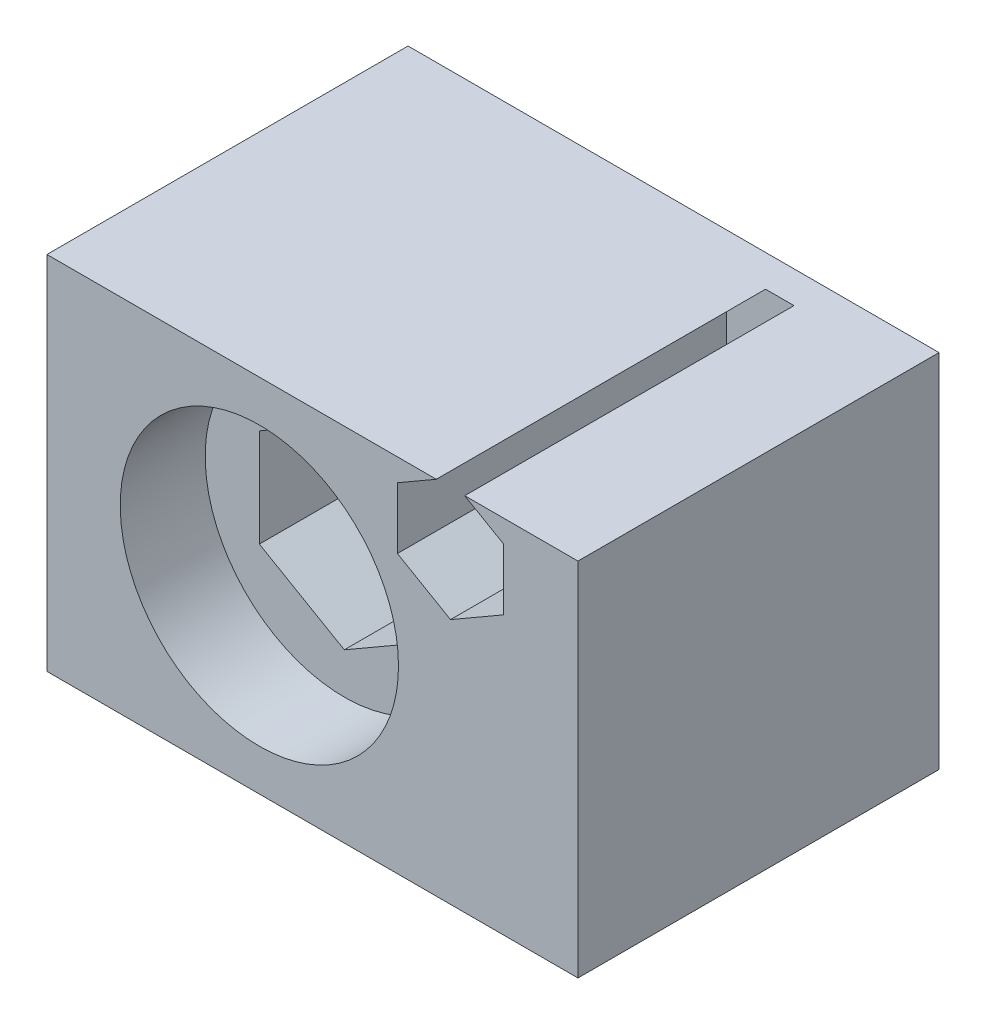
from build123d import *

# Parameters (mm, degrees)
SKETCH_1_W          = 18
SKETCH_1_H          = 18
EXTRUDE_1_DEPTH     = 25
SKETCH_2_R          = 6.55
CUT_EXTRUDE_1_DEPTH = 4.5
CUT_EXTRUDE_2_DEPTH = 11.7
CUT_EXTRUDE_3_DEPTH = 16
SKETCH_6_W          = 18
SKETCH_6_H          = 18
SKETCH_6_W_2        = 17
SKETCH_6_H_2        = 17
CUT_EXTRUDE_5_DEPTH = 26


with BuildPart() as part:
    # 草图1 → 凸台-拉伸1 (new body)
    with BuildSketch(Plane(origin=(0, 0, 0), x_dir=(0, 0, -1), z_dir=(1, 0, 0))):
        with Locations((9, 9)):
            Rectangle(SKETCH_1_W, SKETCH_1_H)
    extrude(amount=EXTRUDE_1_DEPTH)

    # 草图2 → 切除-拉伸1 (cut)
    with BuildSketch(Plane.XY):
        with Locations((10, 9)):
            Circle(SKETCH_2_R)
    extrude(amount=-CUT_EXTRUDE_1_DEPTH, mode=Mode.SUBTRACT)

    # 草图3 → 切除-拉伸2 (cut)
    with BuildSketch(Plane.XY.offset(-4.5)):
        Polygon((10, 13.618802154), (6, 11.309401077), (6, 6.690598923), (10, 4.381197846), (14, 6.690598923), (14, 11.309401077), align=None)
    extrude(amount=-CUT_EXTRUDE_2_DEPTH, mode=Mode.SUBTRACT)

    # 草图4 → 切除-拉伸3 (cut)
    with BuildSketch(Plane.XY):
        Polygon((19, 17.886751346), (16.5, 16.443375673), (16.5, 13.556624327), (19, 12.113248654), (21.5, 13.556624327), (21.5, 16.443375673), align=None)
    extrude(amount=-CUT_EXTRUDE_3_DEPTH, mode=Mode.SUBTRACT)

    # 草图6 → 切除-拉伸5 (cut, through all)
    with BuildSketch(Plane.ZY):
        with Locations((-9, 9)):
            Rectangle(SKETCH_6_W, SKETCH_6_H)
        with Locations((-9, 9)):
            Rectangle(SKETCH_6_W_2, SKETCH_6_H_2, mode=Mode.SUBTRACT)
    extrude(amount=-CUT_EXTRUDE_5_DEPTH, mode=Mode.SUBTRACT)


solid = part.part
